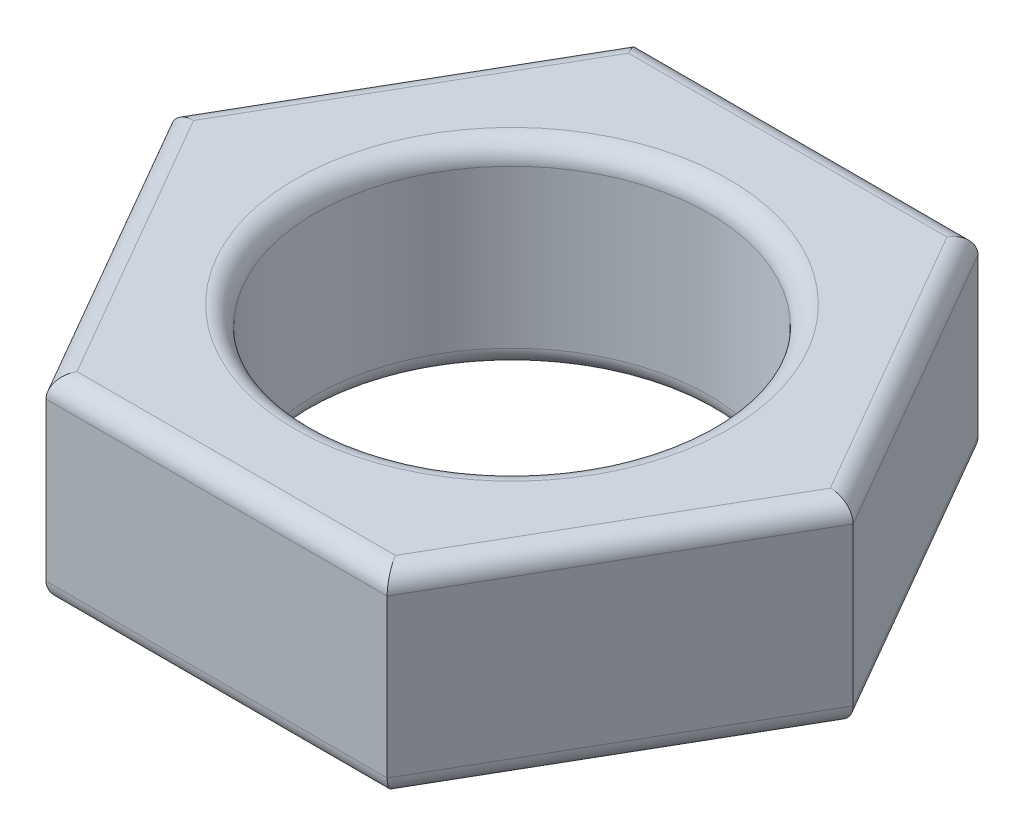
from build123d import *

# Parameters (mm, degrees)
SKETCH1_R           = 5
BOSS_EXTRUDE1_DEPTH = 5
FILLET1_R           = 0.5


with BuildPart() as part:
    # Sketch1 → Boss-Extrude1 (new body)
    with BuildSketch(Plane(origin=(0, 0, 0), x_dir=(1, 0, 0), z_dir=(0, 1, 0))):
        Polygon((4.330127019, -7.5), (8.660254038, 0), (4.330127019, 7.5), (-4.330127019, 7.5), (-8.660254038, 0), (-4.330127019, -7.5), align=None)
        Circle(SKETCH1_R, mode=Mode.SUBTRACT)
    extrude(amount=BOSS_EXTRUDE1_DEPTH)

    # Fillet1
    fillet1_edges = [part.edges().sort_by_distance(p)[0] for p in [
        (6.495190528, 5, -3.75),
        (0, 5, -7.5),
        (-6.495190528, 5, -3.75),
        (-5, 0, 0),
        (-5, 5, 0),
        (-6.495190528, 5, 3.75),
        (0, 5, 7.5),
        (-6.495190528, 0, 3.75),
        (-6.495190528, 0, -3.75),
        (0, 0, -7.5),
        (6.495190528, 5, 3.75),
        (6.495190528, 0, -3.75),
        (6.495190528, 0, 3.75),
        (0, 0, 7.5),
    ]]
    fillet(fillet1_edges, radius=FILLET1_R)


solid = part.part
